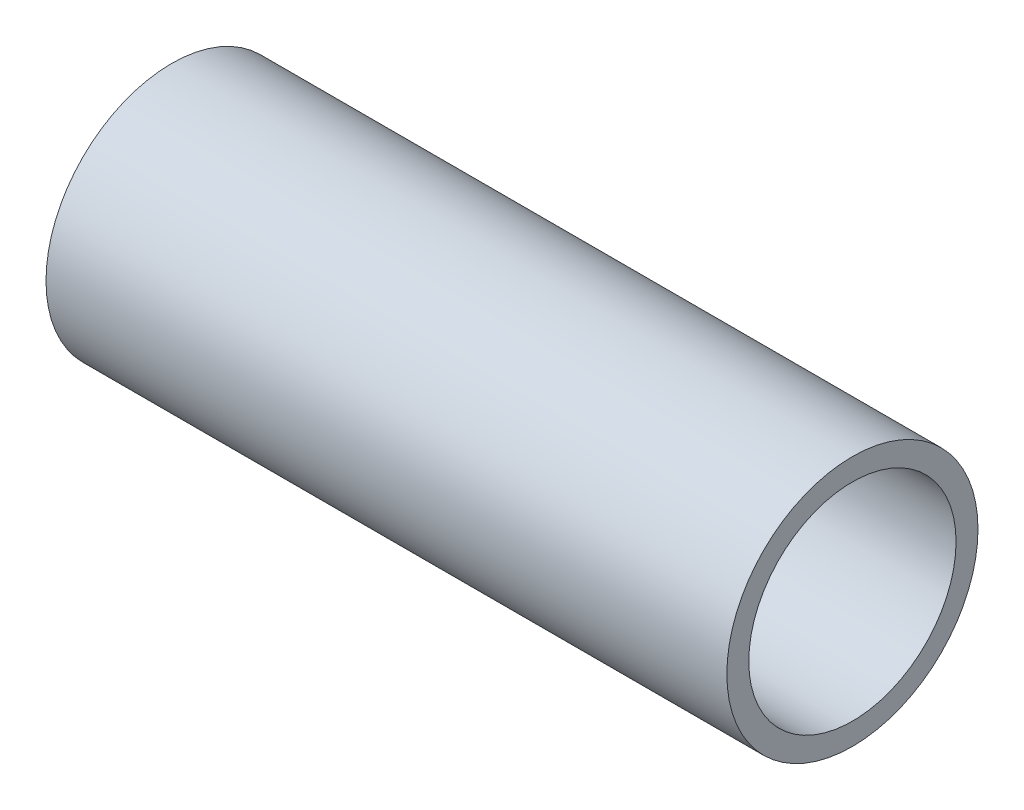
from build123d import *

# Parameters (mm, degrees)
SKETCH1_W = 114.3
SKETCH1_H = 3.683


with BuildPart() as part:
    # Sketch1 → Revolve1 (revolve)
    with BuildSketch(Plane.XY):
        with Locations((57.15, 19.2405)):
            Rectangle(SKETCH1_W, SKETCH1_H)
    revolve(axis=Axis((-25.002792604, 0, 0), (1, 0, 0)))


solid = part.part
